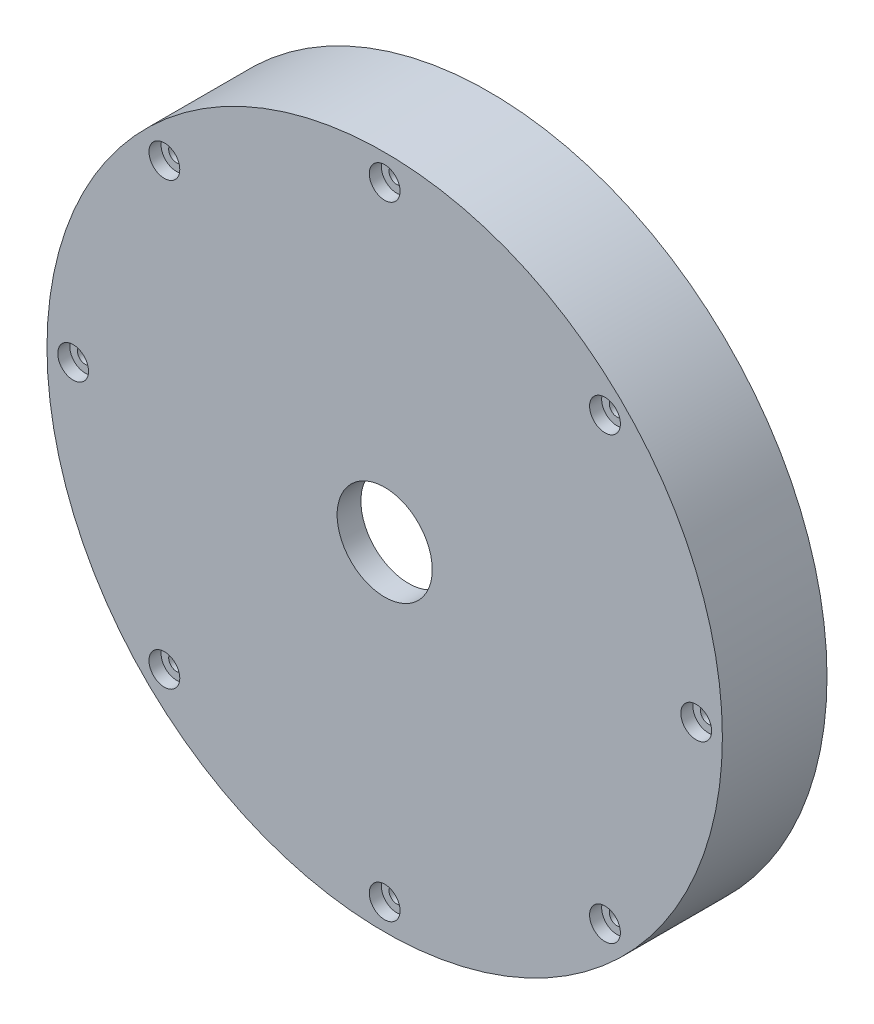
from build123d import *

# Parameters (mm, degrees)
SKETCH1_R           = 71
SKETCH1_R_2         = 60
BOSS_EXTRUDE1_DEPTH = 17
SKETCH2_R           = 71
SKETCH2_R_2         = 10
BOSS_EXTRUDE2_DEPTH = 5
SKETCH5_R           = 1.63703
CUT_EXTRUDE1_DEPTH  = 23
SKETCH6_R           = 3.2385
CUT_EXTRUDE2_DEPTH  = 2.54


with BuildPart() as part:
    # Sketch1 → Boss-Extrude1 (new body)
    with BuildSketch(Plane.XY):
        Circle(SKETCH1_R)
        Circle(SKETCH1_R_2, mode=Mode.SUBTRACT)
    extrude(amount=BOSS_EXTRUDE1_DEPTH)

    # Sketch2 → Boss-Extrude2 (add)
    with BuildSketch(Plane.XY.offset(17)):
        Circle(SKETCH2_R)
        Circle(SKETCH2_R_2, mode=Mode.SUBTRACT)
    extrude(amount=BOSS_EXTRUDE2_DEPTH)

    # Sketch5 → Cut-Extrude1 (cut, through all)
    with BuildSketch(Plane.XY.offset(22)):
        with Locations((0, 65.5)):
            Circle(SKETCH5_R)
        with Locations((46.315494168, 46.315494168)):
            Circle(SKETCH5_R)
        with Locations((65.5, 0)):
            Circle(SKETCH5_R)
        with Locations((46.315494168, -46.315494168)):
            Circle(SKETCH5_R)
        with Locations((0, -65.5)):
            Circle(SKETCH5_R)
        with Locations((-46.315494168, -46.315494168)):
            Circle(SKETCH5_R)
        with Locations((-65.5, 0)):
            Circle(SKETCH5_R)
        with Locations((-46.315494168, 46.315494168)):
            Circle(SKETCH5_R)
    extrude(amount=-CUT_EXTRUDE1_DEPTH, mode=Mode.SUBTRACT)

    # Sketch6 → Cut-Extrude2 (cut)
    with BuildSketch(Plane.XY.offset(22)):
        with Locations((0, 65.5)):
            Circle(SKETCH6_R)
        with Locations((46.315494168, 46.315494168)):
            Circle(SKETCH6_R)
        with Locations((65.5, 0)):
            Circle(SKETCH6_R)
        with Locations((46.315494168, -46.315494168)):
            Circle(SKETCH6_R)
        with Locations((0, -65.5)):
            Circle(SKETCH6_R)
        with Locations((-46.315494168, -46.315494168)):
            Circle(SKETCH6_R)
        with Locations((-65.5, 0)):
            Circle(SKETCH6_R)
        with Locations((-46.315494168, 46.315494168)):
            Circle(SKETCH6_R)
    extrude(amount=-CUT_EXTRUDE2_DEPTH, mode=Mode.SUBTRACT)


solid = part.part
